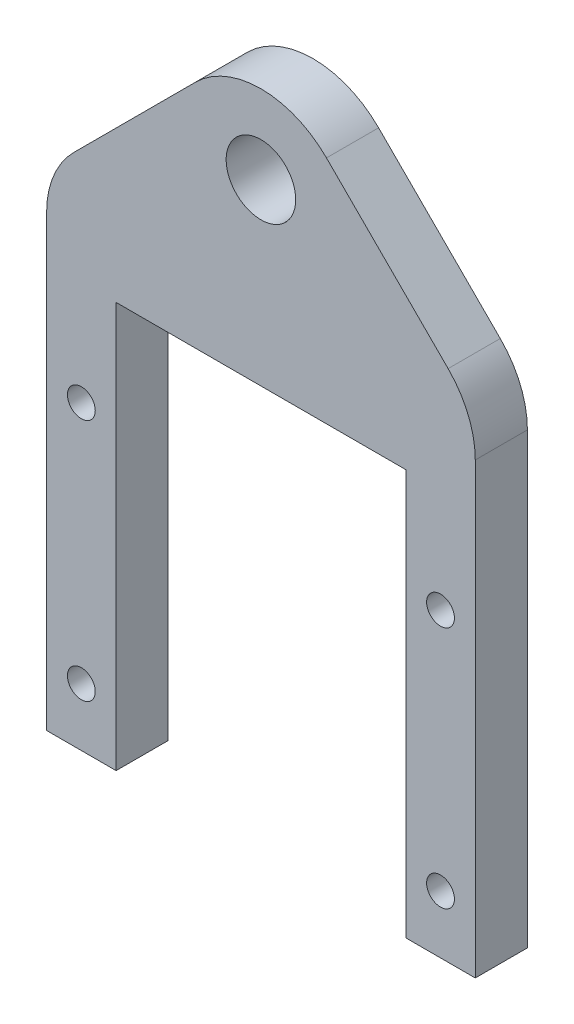
from build123d import *

# Parameters (mm, degrees)
SKETCH_1_R      = 3
SKETCH_1_R_2    = 1.2
EXTRUDE_1_DEPTH = 4.5
FILLET_1_R      = 8


with BuildPart() as part:
    # 草图1 → 凸台-拉伸1 (new body)
    with BuildSketch(Plane.XY):
        Polygon((-12.5, 0), (-18.5, 0), (-18.5, 42.034916596), (0, 60.534916596), (18.5, 42.034916596), (18.5, 0), (12.5, 0), (12.5, 35), (-12.5, 35), align=None)
        with Locations((0, 50.421397557)):
            Circle(SKETCH_1_R, mode=Mode.SUBTRACT)
        with Locations((-15.5, 5)):
            Circle(SKETCH_1_R_2, mode=Mode.SUBTRACT)
        with Locations((-15.5, 26)):
            Circle(SKETCH_1_R_2, mode=Mode.SUBTRACT)
        with Locations((15.5, 5)):
            Circle(SKETCH_1_R_2, mode=Mode.SUBTRACT)
        with Locations((15.5, 26)):
            Circle(SKETCH_1_R_2, mode=Mode.SUBTRACT)
    extrude(amount=EXTRUDE_1_DEPTH)

    # 圆角1
    fillet_1_edges = [part.edges().sort_by_distance(p)[0] for p in [
        (-18.5, 42.034916596, 2.25),
        (0, 60.534916596, 2.25),
        (18.5, 42.034916596, 2.25),
    ]]
    fillet(fillet_1_edges, radius=FILLET_1_R)


solid = part.part
